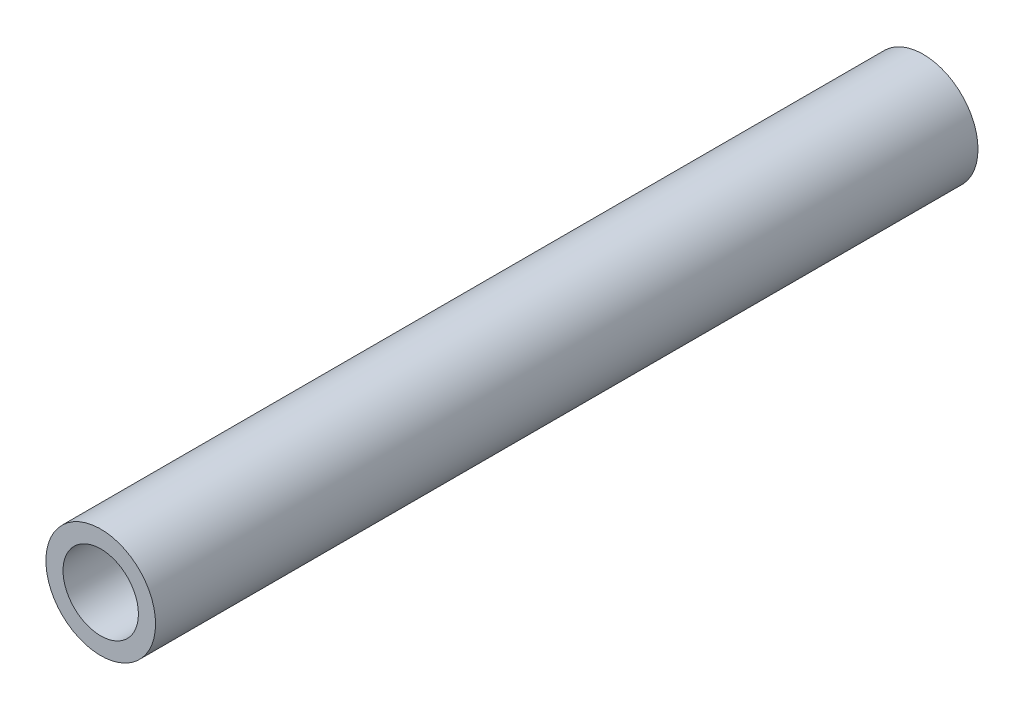
from build123d import *

# Parameters (mm, degrees)
SKETCH1_R           = 12.7
SKETCH1_R_2         = 8.73125
BOSS_EXTRUDE1_DEPTH = 190.5


with BuildPart() as part:
    # Sketch1 → Boss-Extrude1 (new body)
    with BuildSketch(Plane.XY):
        Circle(SKETCH1_R)
        Circle(SKETCH1_R_2, mode=Mode.SUBTRACT)
    extrude(amount=BOSS_EXTRUDE1_DEPTH)


solid = part.part
